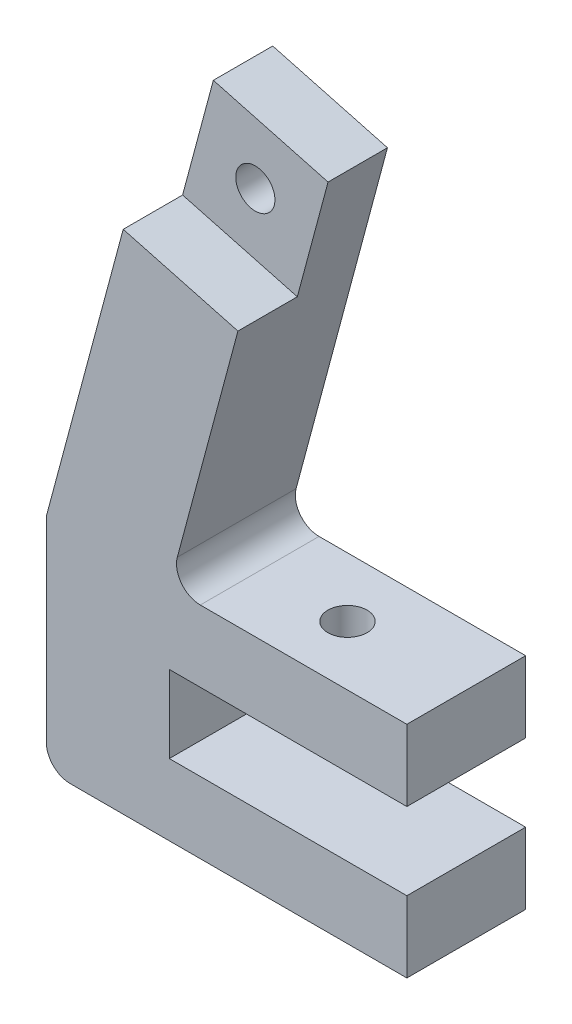
from build123d import *

# Parameters (mm, degrees)
EXTRUDE_1_DEPTH        = 10
CUT_EXTRUDE_1_DEPTH    = 5
FILLET_1_R             = 2
HOLE_WIZARD_M4_1_D     = 3.3
HOLE_WIZARD_M4_1_DEPTH = 6
HOLE_WIZARD_M4_2_D     = 3.3
FILLET_2_R             = 2
SKETCH_23_R            = 4
CUT_EXTRUDE_3_DEPTH    = 1


with BuildPart() as part:
    # 草图1 → 凸台-拉伸1 (new body)
    with BuildSketch(Plane.XY):
        Polygon((0, 0), (0, 6), (-20, 6), (-20, 12.5), (0, 12.5), (0, 18.5), (-20, 18.5), (-11.634836963, 49.719213469), (-21.294095226, 52.30740392), (-30.352761804, 18.5), (-30.352761804, 0), align=None)
    extrude(amount=EXTRUDE_1_DEPTH)

    # 草图2 → 切除-拉伸1 (cut)
    with BuildSketch(Plane.XY.offset(10)):
        Polygon((-21.294095226, 52.30740392), (-11.634836963, 49.719213469), (-14.223027414, 40.059955206), (-23.882285677, 42.648145657), align=None)
    extrude(amount=-CUT_EXTRUDE_1_DEPTH, mode=Mode.SUBTRACT)

    # 圆角1
    fillet_1_edges = [part.edges().sort_by_distance(p)[0] for p in [
        (-20, 18.5, 5),
    ]]
    fillet(fillet_1_edges, radius=FILLET_1_R)

    # M4 螺纹孔1
    with Locations(Plane(origin=(0, 18.5, 0), x_dir=(1, 0, 0), z_dir=(0, 1, 0))):
        with Locations((-10, -5)):
            Hole(HOLE_WIZARD_M4_1_D / 2, depth=HOLE_WIZARD_M4_1_DEPTH)

    # M4 螺纹孔2 (through all)
    with Locations(Plane.XY.offset(5)):
        with Locations((-17.75856132, 46.183679563)):
            Hole(HOLE_WIZARD_M4_2_D / 2)

    # 圆角2
    fillet_2_edges = [part.edges().sort_by_distance(p)[0] for p in [
        (-30.352761804, 0, 5),
    ]]
    fillet(fillet_2_edges, radius=FILLET_2_R)

    # 草图23 → 切除-拉伸3 (cut)
    with BuildSketch(Plane(origin=(0, 0, 0), x_dir=(-1, 0, 0), z_dir=(0, 0, -1))):
        with Locations((17.75856132, 46.183679563)):
            Circle(SKETCH_23_R)
    extrude(amount=-CUT_EXTRUDE_3_DEPTH, mode=Mode.SUBTRACT)


solid = part.part
